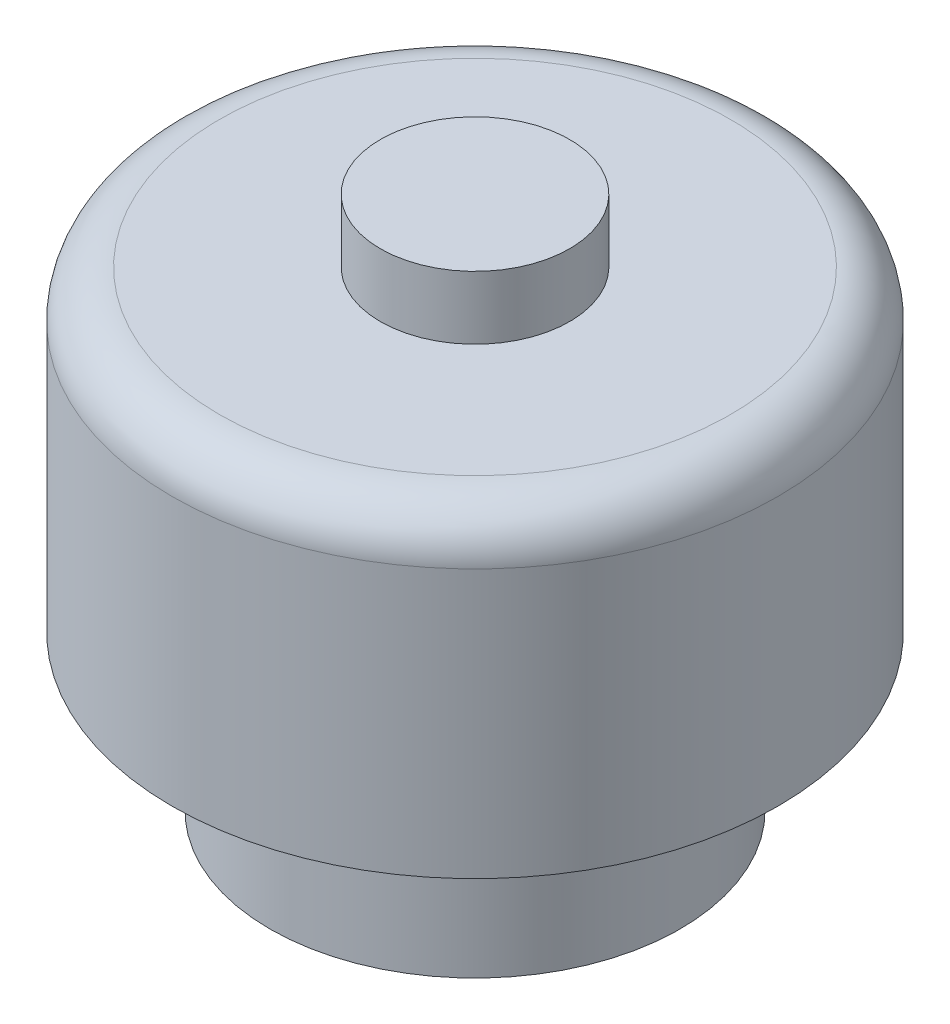
from build123d import *

# Parameters (mm, degrees)
SKETCH1_R           = 3.25
BOSS_EXTRUDE1_DEPTH = 2.46
SKETCH2_R           = 1.75
CUT_EXTRUDE1_DEPTH  = 2.5
SKETCH6_R           = 4.8
BOSS_EXTRUDE2_DEPTH = 5
FILLET2_R           = 0.75
SKETCH7_R           = 1.5
BOSS_EXTRUDE3_DEPTH = 1


with BuildPart() as part:
    # Sketch1 → Boss-Extrude1 (new body)
    with BuildSketch(Plane(origin=(0, 0, 0), x_dir=(1, 0, 0), z_dir=(0, 1, 0))):
        Circle(SKETCH1_R)
    extrude(amount=BOSS_EXTRUDE1_DEPTH)

    # Sketch2 → Cut-Extrude1 (cut)
    with BuildSketch(Plane.XZ):
        Circle(SKETCH2_R)
    extrude(amount=-CUT_EXTRUDE1_DEPTH, mode=Mode.SUBTRACT)

    # Sketch6 → Boss-Extrude2 (add)
    with BuildSketch(Plane(origin=(0, 2.46, 0), x_dir=(1, 0, 0), z_dir=(0, 1, 0))):
        Circle(SKETCH6_R)
    extrude(amount=BOSS_EXTRUDE2_DEPTH)

    # Fillet2
    fillet2_edges = [part.edges().sort_by_distance(p)[0] for p in [
        (-4.8, 7.46, 0),
    ]]
    fillet(fillet2_edges, radius=FILLET2_R)

    # Sketch7 → Boss-Extrude3 (add)
    with BuildSketch(Plane(origin=(0, 7.46, 0), x_dir=(1, 0, 0), z_dir=(0, 1, 0))):
        Circle(SKETCH7_R)
    extrude(amount=BOSS_EXTRUDE3_DEPTH)


solid = part.part
